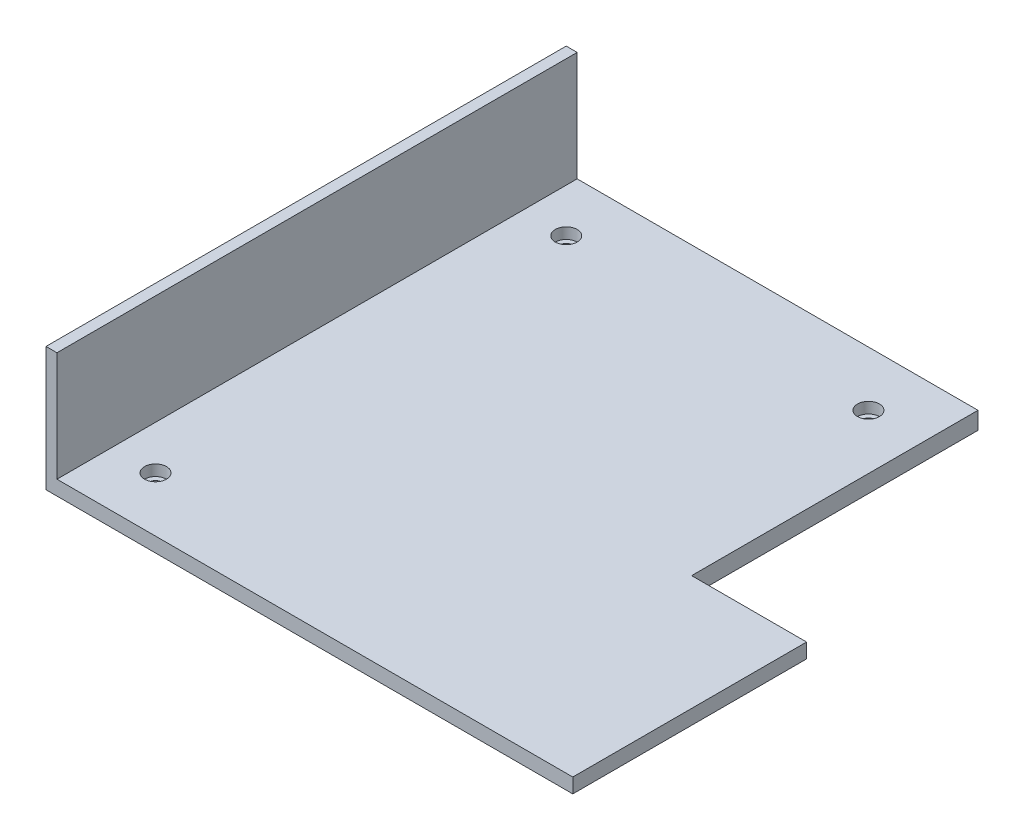
from build123d import *

# Parameters (mm, degrees)
SKETCH1_W                      = 192.4
SKETCH1_H                      = 190
BOSS_EXTRUDE1_DEPTH            = 6.35
BOSS_EXTRUDE2_DEPTH            = 40
CUT_EXTRUDE1_REACH             = 8.35
SKETCH4_W                      = 42
SKETCH4_H                      = 104.6
CBORE_FOR_M4_SHCS1_D           = 4.5
CBORE_FOR_M4_SHCS1_DEPTH       = 6.35
CBORE_FOR_M4_SHCS1_CBORE_D     = 8
CBORE_FOR_M4_SHCS1_CBORE_DEPTH = 4
CHAMFER1_SIZE                  = 1


with BuildPart() as part:
    # Sketch1 → Boss-Extrude1 (new body)
    with BuildSketch(Plane(origin=(0, 0, 0), x_dir=(1, 0, 0), z_dir=(0, 1, 0))):
        Rectangle(SKETCH1_W, SKETCH1_H)
    extrude(amount=BOSS_EXTRUDE1_DEPTH)

    # Sketch2 → Boss-Extrude2 (add)
    with BuildSketch(Plane(origin=(0, 6.35, 0), x_dir=(1, 0, 0), z_dir=(0, 1, 0))):
        Polygon((-92.2, 91), (-92.2, -91), (-92.2, -95), (-96.2, -95), (-96.2, 95), (-92.2, 95), align=None)
    extrude(amount=BOSS_EXTRUDE2_DEPTH)

    # Sketch4 → Cut-Extrude1 (cut, up to next)
    with BuildSketch(Plane(origin=(0, 6.35, 0), x_dir=(1, 0, 0), z_dir=(0, 1, 0)), mode=Mode.PRIVATE) as cut_extrude1_sk1:
        with Locations((75.2, 42.7)):
            Rectangle(SKETCH4_W, SKETCH4_H)
    cut_extrude1_tool1 = extrude(cut_extrude1_sk1.sketch, amount=-CUT_EXTRUDE1_REACH, mode=Mode.PRIVATE) & part.part
    add(cut_extrude1_tool1.solids().sort_by_distance((75.2, 6.35, -42.7))[0], mode=Mode.SUBTRACT)

    # CBORE for M4 SHCS1
    with Locations(Plane(origin=(0, 6.35, 0), x_dir=(1, 0, 0), z_dir=(0, 1, 0))):
        with Locations((34.2, 75), (-76.2, 75), (-76.2, -75)):
            CounterBoreHole(CBORE_FOR_M4_SHCS1_D / 2, CBORE_FOR_M4_SHCS1_CBORE_D / 2, CBORE_FOR_M4_SHCS1_CBORE_DEPTH, depth=CBORE_FOR_M4_SHCS1_DEPTH)

    # Chamfer1
    chamfer1_edges = [part.edges().sort_by_distance(p)[0] for p in [
        (0, 0, 95),
        (96.2, 0, 52.3),
    ]]
    chamfer(chamfer1_edges, length=CHAMFER1_SIZE)


solid = part.part
